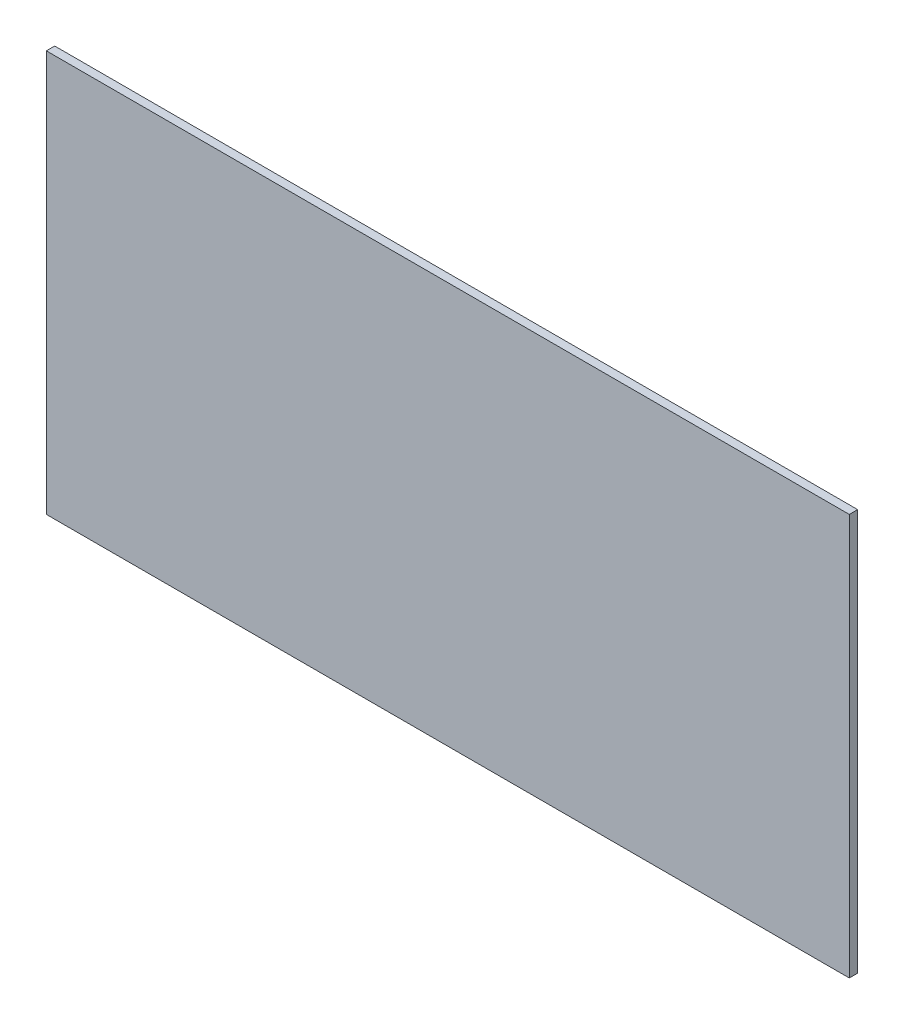
from build123d import *

# Parameters (mm, degrees)
SKETCH1_W           = 2438.4
SKETCH1_H           = 1219.2
BOSS_EXTRUDE1_DEPTH = 25.4


with BuildPart() as part:
    # Sketch1 → Boss-Extrude1 (new body)
    with BuildSketch(Plane.XY):
        with Locations((1219.2, -609.6)):
            Rectangle(SKETCH1_W, SKETCH1_H)
    extrude(amount=BOSS_EXTRUDE1_DEPTH)


solid = part.part
